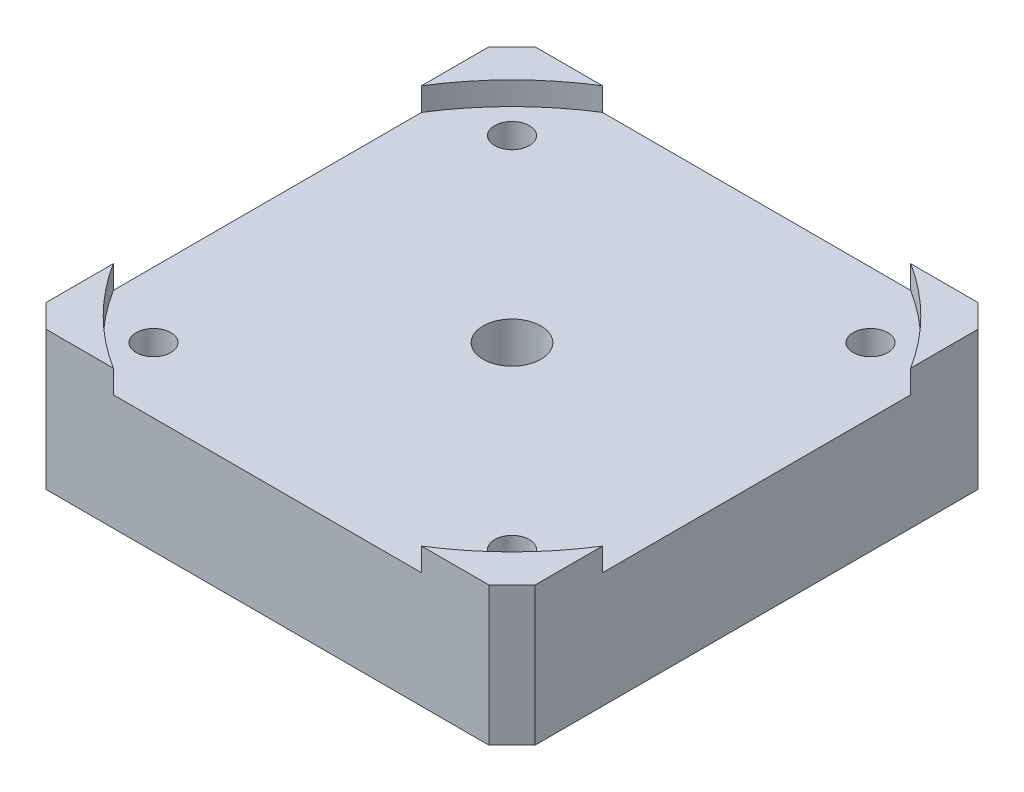
from build123d import *

# Parameters (mm, degrees)
CROQUIS1_W              = 42.3
CROQUIS1_H              = 42.3
SALIENTE_EXTRUIR1_DEPTH = 12
CORTAR_EXTRUIR1_DEPTH   = 2
CHAFL_N1_SIZE           = 2
CROQUIS3_R              = 1.5
CORTAR_EXTRUIR2_DEPTH   = 10
CROQUIS4_R              = 12
CORTAR_EXTRUIR3_DEPTH   = 2
CROQUIS5_R              = 11
SALIENTE_EXTRUIR2_DEPTH = 4
CROQUIS6_R              = 3.5
CORTAR_EXTRUIR5_DEPTH   = 2
CROQUIS7_R              = 2.5
CORTAR_EXTRUIR6_DEPTH   = 13


with BuildPart() as part:
    # Croquis1 → Saliente-Extruir1 (new body)
    with BuildSketch(Plane(origin=(0, 0, 0), x_dir=(1, 0, 0), z_dir=(0, 1, 0))):
        Rectangle(CROQUIS1_W, CROQUIS1_H)
    extrude(amount=SALIENTE_EXTRUIR1_DEPTH)

    # Croquis2 → Cortar-Extruir1 (cut)
    with BuildSketch(Plane(origin=(0, 12, 0), x_dir=(1, 0, 0), z_dir=(0, 1, 0))):
        with BuildLine():
            Line((-21.15, 13.329572386), (-21.15, -13.329572386))
            ThreePointArc((-21.15, -13.329572386), (-17.67766953, -17.67766953), (-13.329572386, -21.15))
            Line((-13.329572386, -21.15), (13.329572386, -21.15))
            ThreePointArc((13.329572386, -21.15), (17.67766953, -17.67766953), (21.15, -13.329572386))
            Line((21.15, -13.329572386), (21.15, 13.329572386))
            ThreePointArc((21.15, 13.329572386), (17.67766953, 17.67766953), (13.329572386, 21.15))
            Line((13.329572386, 21.15), (-13.329572386, 21.15))
            ThreePointArc((-13.329572386, 21.15), (-17.67766953, 17.67766953), (-21.15, 13.329572386))
        make_face()
    extrude(amount=-CORTAR_EXTRUIR1_DEPTH, mode=Mode.SUBTRACT)

    # Chaflán1
    chafl_n1_edges = [part.edges().sort_by_distance(p)[0] for p in [
        (21.15, 6, 21.15),
        (-21.15, 6, 21.15),
        (-21.15, 6, -21.15),
        (21.15, 6, -21.15),
    ]]
    chamfer(chafl_n1_edges, length=CHAFL_N1_SIZE)

    # Croquis3 → Cortar-Extruir2 (cut)
    with BuildSketch(Plane.XZ):
        with Locations((-15.5, 15.5)):
            Circle(CROQUIS3_R)
        with Locations((-15.5, -15.5)):
            Circle(CROQUIS3_R)
        with Locations((15.5, -15.5)):
            Circle(CROQUIS3_R)
        with Locations((15.5, 15.5)):
            Circle(CROQUIS3_R)
    extrude(amount=-CORTAR_EXTRUIR2_DEPTH, mode=Mode.SUBTRACT)

    # Croquis4 → Cortar-Extruir3 (cut)
    with BuildSketch(Plane.XZ):
        Circle(CROQUIS4_R)
    extrude(amount=-CORTAR_EXTRUIR3_DEPTH, mode=Mode.SUBTRACT)

    # Croquis5 → Saliente-Extruir2 (add)
    with BuildSketch(Plane.XZ.offset(-2)):
        Circle(CROQUIS5_R)
    extrude(amount=SALIENTE_EXTRUIR2_DEPTH)

    # Croquis6 → Cortar-Extruir5 (cut)
    with BuildSketch(Plane.XZ.offset(2)):
        Circle(CROQUIS6_R)
    extrude(amount=-CORTAR_EXTRUIR5_DEPTH, mode=Mode.SUBTRACT)

    # Croquis7 → Cortar-Extruir6 (cut, through all)
    with BuildSketch(Plane.XZ):
        Circle(CROQUIS7_R)
    extrude(amount=-CORTAR_EXTRUIR6_DEPTH, mode=Mode.SUBTRACT)


solid = part.part
